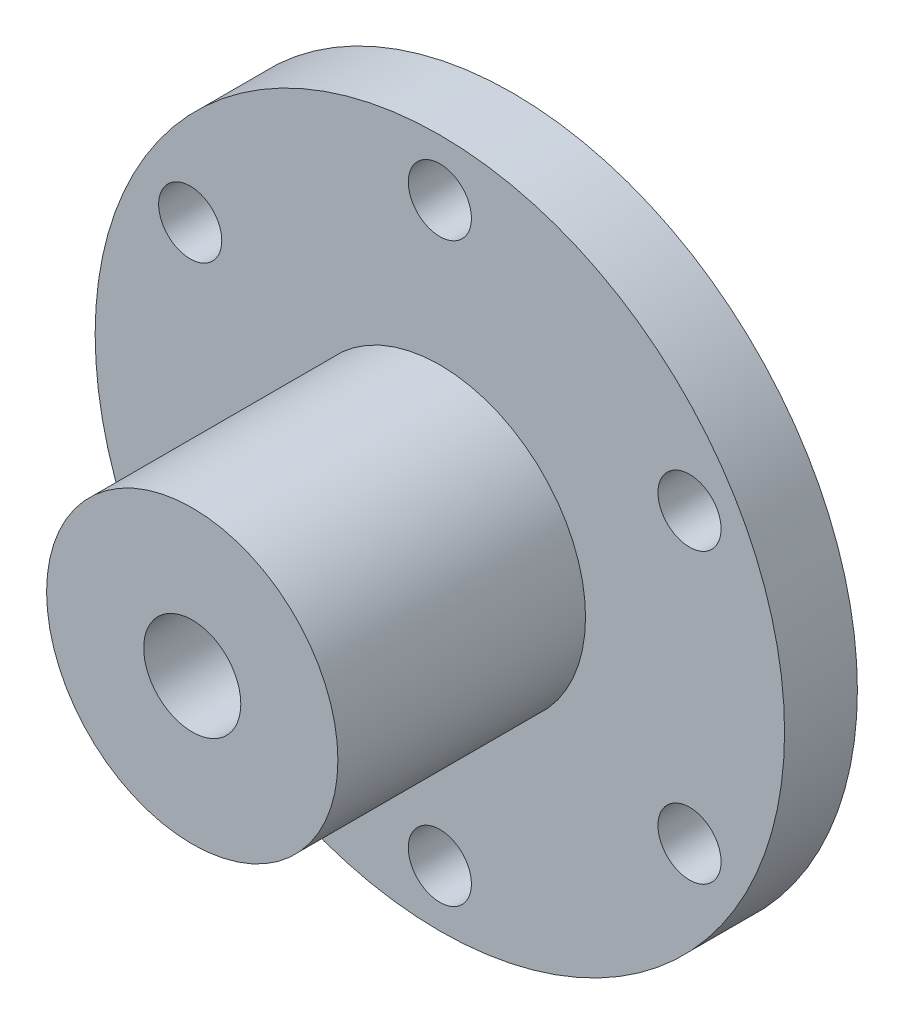
from build123d import *

# Parameters (mm, degrees)
SKETCH1_R           = 28.4
SKETCH1_R_2         = 2.6
SKETCH1_R_3         = 4
BOSS_EXTRUDE1_DEPTH = 6
SKETCH2_R           = 12
SKETCH2_R_2         = 4
BOSS_EXTRUDE2_DEPTH = 20.4


with BuildPart() as part:
    # Sketch1 → Boss-Extrude1 (new body)
    with BuildSketch(Plane.XY):
        Circle(SKETCH1_R)
        with Locations((0, 23.75)):
            Circle(SKETCH1_R_2, mode=Mode.SUBTRACT)
        with Locations((20.56810334, 11.875)):
            Circle(SKETCH1_R_2, mode=Mode.SUBTRACT)
        with Locations((20.56810334, -11.875)):
            Circle(SKETCH1_R_2, mode=Mode.SUBTRACT)
        with Locations((0, -23.75)):
            Circle(SKETCH1_R_2, mode=Mode.SUBTRACT)
        with Locations((-20.56810334, -11.875)):
            Circle(SKETCH1_R_2, mode=Mode.SUBTRACT)
        with Locations((-20.56810334, 11.875)):
            Circle(SKETCH1_R_2, mode=Mode.SUBTRACT)
        Circle(SKETCH1_R_3, mode=Mode.SUBTRACT)
    extrude(amount=BOSS_EXTRUDE1_DEPTH)

    # Sketch2 → Boss-Extrude2 (add)
    with BuildSketch(Plane.XY.offset(6)):
        Circle(SKETCH2_R)
        Circle(SKETCH2_R_2, mode=Mode.SUBTRACT)
    extrude(amount=BOSS_EXTRUDE2_DEPTH)


solid = part.part
